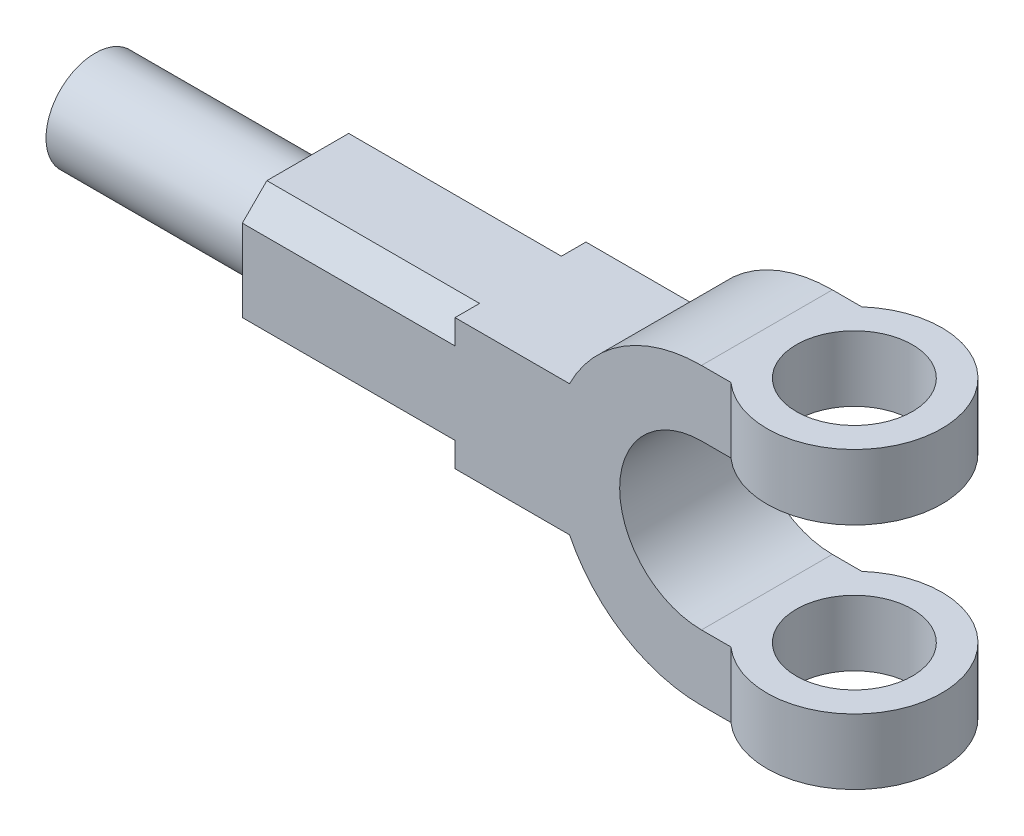
from build123d import *

# Parameters (mm, degrees)
BOSS_EXTRUDE1_DEPTH = 20
SKETCH2_R           = 26.722222222
SKETCH2_R_2         = 17.722222222
BOSS_EXTRUDE2_DEPTH = 20
CUT_EXTRUDE1_DEPTH  = 65
SKETCH4_R           = 15
BOSS_EXTRUDE3_DEPTH = 65
CIRPATTERN1_COUNT   = 4


with BuildPart() as part:
    # Sketch1 → Boss-Extrude1 (new body, symmetric)
    with BuildSketch(Plane.XY):
        with BuildLine():
            ThreePointArc((0, -25), (-25, 0), (0, 25))
            Line((0, 25), (9, 25))
            Line((9, 25), (9, 45))
            Line((9, 45), (0, 45))
            ThreePointArc((0, 45), (-23.717082451, 38.242646352), (-40.311288741, 20))
            Line((-40.311288741, 20), (-140.311288741, 20))
            Line((-140.311288741, 20), (-140.311288741, -20))
            Line((-140.311288741, -20), (-40.311288741, -20))
            ThreePointArc((-40.311288741, -20), (-23.717082451, -38.242646352), (0, -45))
            Line((0, -45), (9, -45))
            Line((9, -45), (9, -25))
            Line((9, -25), (0, -25))
        make_face()
    extrude(amount=BOSS_EXTRUDE1_DEPTH, both=True)

    # Sketch2 → Boss-Extrude2 (add)
    with BuildSketch(Plane(origin=(0, 45, 0), x_dir=(1, 0, 0), z_dir=(0, 1, 0))):
        with Locations((26.722222222, 0)):
            Circle(SKETCH2_R)
        with Locations((26.722222222, 0)):
            Circle(SKETCH2_R_2, mode=Mode.SUBTRACT)
    boss_extrude2 = extrude(amount=-BOSS_EXTRUDE2_DEPTH)

    # Mirror1: Boss-Extrude2 across plane
    add(boss_extrude2.mirror(Plane.ZX))

    # Sketch3 → Cut-Extrude1 (cut)
    with BuildSketch(Plane.ZY.offset(140.311288741)):
        Polygon((-12.5, 20), (-20, 20), (-20, 12.5), align=None)
    cut_extrude1 = extrude(amount=-CUT_EXTRUDE1_DEPTH, mode=Mode.SUBTRACT)

    # Sketch4 → Boss-Extrude3 (add)
    with BuildSketch(Plane.ZY.offset(140.311288741)):
        Circle(SKETCH4_R)
    extrude(amount=BOSS_EXTRUDE3_DEPTH)

    # CirPattern1: Cut-Extrude1 ×4 about axis
    cirpattern1_axis = Axis((0, 0, 0), (1, 0, 0))
    for i in range(1, CIRPATTERN1_COUNT):
        add(cut_extrude1.rotate(cirpattern1_axis, i * 360 / CIRPATTERN1_COUNT), mode=Mode.SUBTRACT)


solid = part.part
